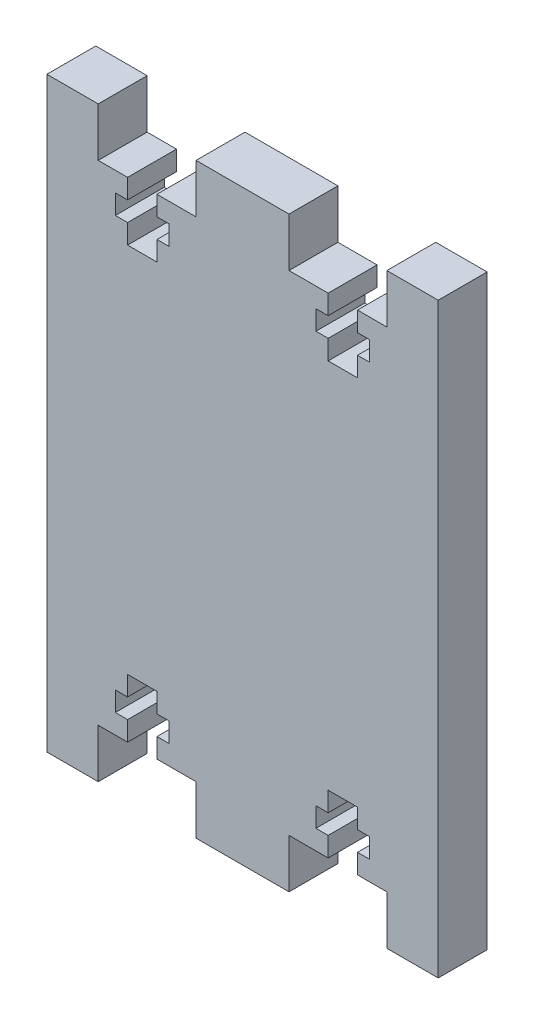
from build123d import *

# Parameters (mm, degrees)
SKETCH1_W           = 40
SKETCH1_H           = 55
BOSS_EXTRUDE1_DEPTH = 5
SKETCH2_OUTSIDE_W   = 55.638
SKETCH2_OUTSIDE_H   = 70.638
CUT_EXTRUDE1_DEPTH  = 10
SKETCH2_3_W         = 5.25
SKETCH2_3_H         = 5
SKETCH2_3_W_2       = 9.5
BOSS_EXTRUDE2_DEPTH = 5


with BuildPart() as part:
    # Sketch1 → Boss-Extrude1 (new body)
    with BuildSketch(Plane.XY):
        with Locations((-67.136843489, 42.42527276)):
            Rectangle(SKETCH1_W, SKETCH1_H)
    extrude(amount=BOSS_EXTRUDE1_DEPTH)

    # Sketch2 outside → Cut-Extrude1 (cut)
    with BuildSketch(Plane.XY.offset(5)):
        with Locations((-67.137, 42.425)):
            Rectangle(SKETCH2_OUTSIDE_W, SKETCH2_OUTSIDE_H)
        Polygon((-75.886843489, 63.92527276), (-78.886843489, 63.92527276), (-78.886843489, 65.92527276), (-80.136843489, 65.92527276), (-80.136843489, 67.92527276), (-78.886843489, 67.92527276), (-78.886843489, 69.92527276), (-81.886843489, 69.92527276), (-87.136843489, 69.92527276), (-87.136843489, 14.92527276), (-47.136843489, 14.92527276), (-47.136843489, 69.92527276), (-52.386843489, 69.92527276), (-55.386843489, 69.92527276), (-55.386843489, 67.92527276), (-54.136843489, 67.92527276), (-54.136843489, 65.92527276), (-55.386843489, 65.92527276), (-55.386843489, 63.92527276), (-58.386843489, 63.92527276), (-58.386843489, 65.92527276), (-59.636843489, 65.92527276), (-59.636843489, 67.92527276), (-58.386843489, 67.92527276), (-58.386843489, 69.92527276), (-62.386843489, 69.92527276), (-71.886843489, 69.92527276), (-75.886843489, 69.92527276), (-75.886843489, 67.92527276), (-74.636843489, 67.92527276), (-74.636843489, 65.92527276), (-75.886843489, 65.92527276), align=None, mode=Mode.SUBTRACT)
    cut_extrude1 = extrude(amount=-CUT_EXTRUDE1_DEPTH, mode=Mode.SUBTRACT)

    # Sketch2_3 → Boss-Extrude2 (add)
    with BuildSketch(Plane.XY.offset(5)):
        with Locations((-84.511843489, 72.42527276)):
            Rectangle(SKETCH2_3_W, SKETCH2_3_H)
        with Locations((-49.761843489, 72.42527276)):
            Rectangle(SKETCH2_3_W, SKETCH2_3_H)
        with Locations((-67.136843489, 72.42527276)):
            Rectangle(SKETCH2_3_W_2, SKETCH2_3_H)
    boss_extrude2 = extrude(amount=-BOSS_EXTRUDE2_DEPTH)

    # Mirror1: Cut-Extrude1, Boss-Extrude2 across plane
    add(cut_extrude1.mirror(Plane.ZX.offset(44.92527276)), mode=Mode.SUBTRACT)
    add(boss_extrude2.mirror(Plane.ZX.offset(44.92527276)))


solid = part.part
